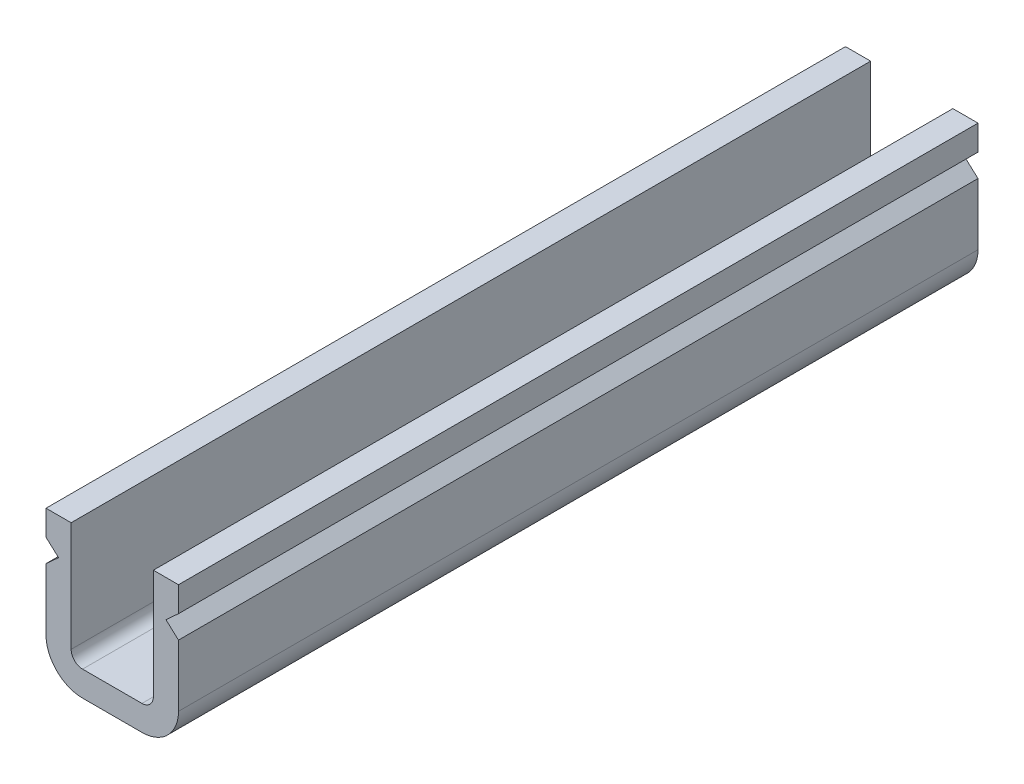
from build123d import *

# Parameters (mm, degrees)
EXTRUSION1_DEPTH = 35


with BuildPart() as part:
    # Esquisse1 → Extrusion1 (new body)
    with BuildSketch(Plane.XY):
        with BuildLine():
            Line((6.8, -6.9), (6.8, -2.1))
            Line((6.8, -2.1), (7.9, -2.1))
            Line((7.9, -2.1), (7.9, -3.2))
            Line((7.9, -3.2), (7.35, -3.7))
            Line((7.35, -3.7), (7.9, -4.2))
            Line((7.9, -4.2), (7.9, -6.9))
            ThreePointArc((7.9, -6.9), (7.43137085, -8.03137085), (6.3, -8.5))
            Line((6.3, -8.5), (3.7, -8.5))
            ThreePointArc((3.7, -8.5), (2.56862915, -8.03137085), (2.1, -6.9))
            Line((2.1, -6.9), (2.1, -4.2))
            Line((2.1, -4.2), (2.65, -3.7))
            Line((2.65, -3.7), (2.1, -3.2))
            Line((2.1, -3.2), (2.1, -2.1))
            Line((2.1, -2.1), (3.2, -2.1))
            Line((3.2, -2.1), (3.2, -6.9))
            ThreePointArc((3.2, -6.9), (3.346446609, -7.253553391), (3.7, -7.4))
            Line((3.7, -7.4), (6.3, -7.4))
            ThreePointArc((6.3, -7.4), (6.653553391, -7.253553391), (6.8, -6.9))
        make_face()
    extrude(amount=EXTRUSION1_DEPTH)


solid = part.part
